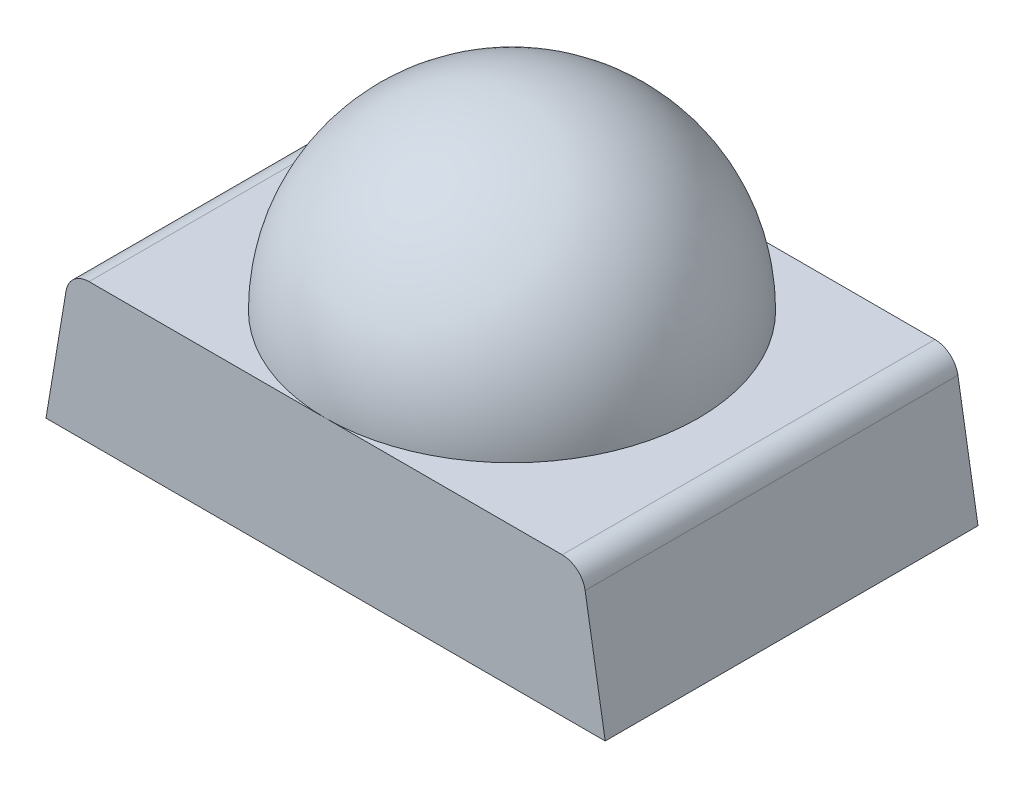
from build123d import *

# Parameters (mm, degrees)
SKETCH1_W           = 1.2
SKETCH1_H           = 0.8
BOSS_EXTRUDE1_DEPTH = 0.3
CUT_EXTRUDE1_DEPTH  = 2.220655562
FILLET1_R           = 0.05


with BuildPart() as part:
    # Sketch1 → Boss-Extrude1 (new body)
    with BuildSketch(Plane(origin=(0, 0, 0), x_dir=(1, 0, 0), z_dir=(0, 1, 0))):
        Rectangle(SKETCH1_W, SKETCH1_H)
    extrude(amount=BOSS_EXTRUDE1_DEPTH)

    # Sketch5 → Revolve1 (revolve)
    with BuildSketch(Plane(origin=(0, 0, 0), x_dir=(0, 0, -1), z_dir=(1, 0, 0))):
        with BuildLine():
            Line((0, 0), (0, 0.7))
            ThreePointArc((0, 0.7), (0.282842712, 0.582842712), (0.4, 0.3))
            Line((0.4, 0.3), (0.4, 0))
            Line((0.4, 0), (0, 0))
        make_face()
    revolve(axis=Axis((0, 0, 0), (0, 1, 0)))

    # Sketch4 → Cut-Extrude1 (cut, through all)
    with BuildSketch(Plane.XY.offset(0.4)):
        Polygon((-0.6, 0), (-0.55, 0.3), (-0.6, 0.3), align=None)
    cut_extrude1 = extrude(amount=-CUT_EXTRUDE1_DEPTH, mode=Mode.SUBTRACT)

    # Mirror1: Cut-Extrude1 across plane
    add(cut_extrude1.mirror(Plane(origin=(0, 0, 0), x_dir=(0, 0, 1), z_dir=(1, 0, 0))), mode=Mode.SUBTRACT)

    # Fillet1
    fillet1_edges = [part.edges().sort_by_distance(p)[0] for p in [
        (0.55, 0.3, 0),
        (-0.55, 0.3, 0),
    ]]
    fillet(fillet1_edges, radius=FILLET1_R)


solid = part.part
